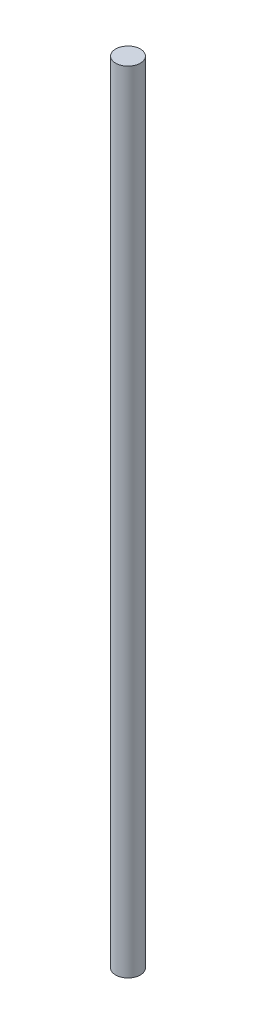
from build123d import *

# Parameters (mm, degrees)
SKETCH1_R           = 1.5875
BOSS_EXTRUDE1_DEPTH = 101.6


with BuildPart() as part:
    # Sketch1 → Boss-Extrude1 (new body)
    with BuildSketch(Plane(origin=(0, 0, 0), x_dir=(1, 0, 0), z_dir=(0, 1, 0))):
        Circle(SKETCH1_R)
    extrude(amount=BOSS_EXTRUDE1_DEPTH)


solid = part.part
